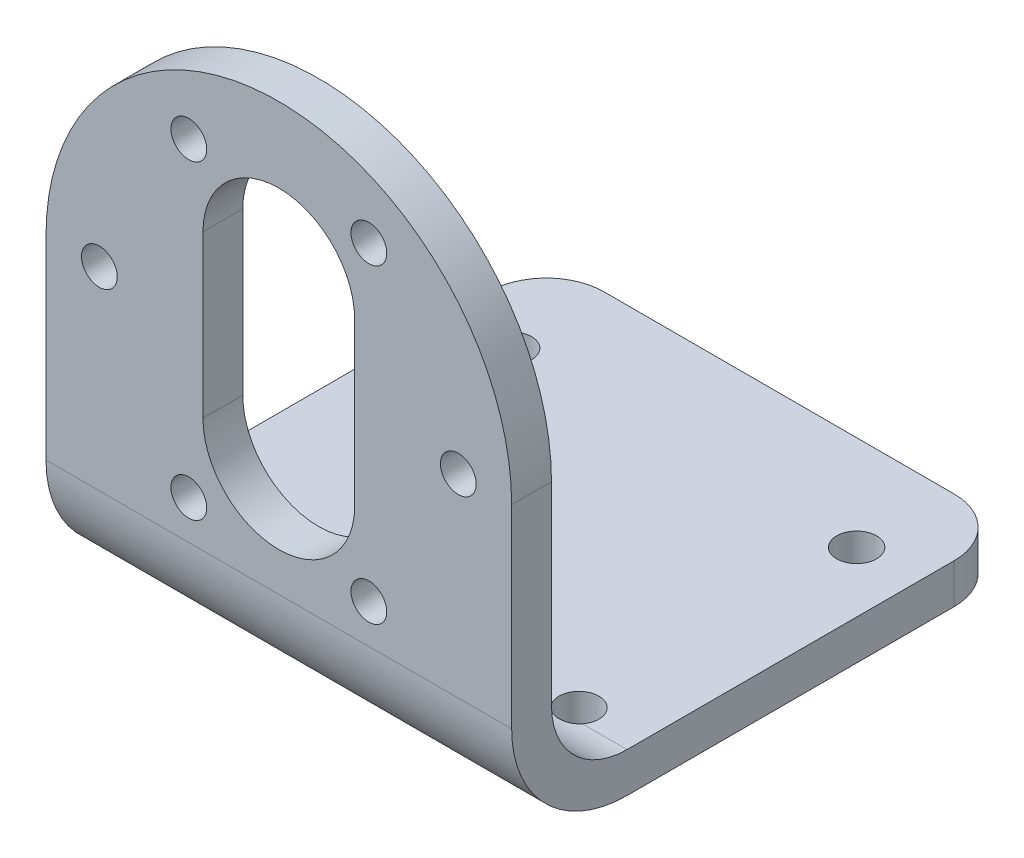
from build123d import *

# Parameters (mm, degrees)
SKETCH1_W               = 40.35
SKETCH1_H               = 43.35
BOSS_EXTRUDE1_DEPTH     = 47
CUT_EXTRUDE2_DEPTH      = 102
FILLET1_R               = 10
CUT_EXTRUDE3_DEPTH      = 102
FILLET2_R               = 5
CUT_EXTRUDE4_DEPTH      = 102
CUT_EXTRUDE4_DEPTH_BACK = 102
SKETCH6_R               = 1.73
CUT_EXTRUDE5_DEPTH      = 102
SKETCH8_R               = 1.55
CUT_EXTRUDE6_DEPTH      = 102


with BuildPart() as part:
    # Sketch1 → Boss-Extrude1 (new body)
    with BuildSketch(Plane(origin=(0, 0, 0), x_dir=(1, 0, 0), z_dir=(0, 1, 0))):
        with Locations((-26.966212793, -29.108023223)):
            Rectangle(SKETCH1_W, SKETCH1_H)
    extrude(amount=BOSS_EXTRUDE1_DEPTH)

    # Sketch3 → Cut-Extrude2 (cut)
    with BuildSketch(Plane.XY.offset(50.783023223)):
        with BuildLine():
            Line((-6.791212793, 47), (-26.966212793, 47))
            ThreePointArc((-26.966212793, 47), (-12.700333482, 41.09087931), (-6.791212793, 26.825))
            Line((-6.791212793, 26.825), (-6.791212793, 47))
        make_face()
        with BuildLine():
            Line((-47.141212793, 47), (-47.141212793, 26.825))
            ThreePointArc((-47.141212793, 26.825), (-41.232092103, 41.09087931), (-26.966212793, 47))
            Line((-26.966212793, 47), (-47.141212793, 47))
        make_face()
    extrude(amount=-CUT_EXTRUDE2_DEPTH, mode=Mode.SUBTRACT)

    # Fillet1
    fillet1_edges = [part.edges().sort_by_distance(p)[0] for p in [
        (-26.966212793, 0, 50.783023223),
    ]]
    fillet(fillet1_edges, radius=FILLET1_R)

    # Sketch5 → Cut-Extrude3 (cut)
    with BuildSketch(Plane.ZY.offset(47.141212793)):
        with BuildLine():
            Line((47.333023223, 59.778436909), (-6.665763497, 59.778436909))
            Line((-6.665763497, 59.778436909), (-6.665763497, 3.45))
            Line((-6.665763497, 3.45), (40.783023223, 3.45))
            ThreePointArc((40.783023223, 3.45), (45.41457264, 5.368450583), (47.333023223, 10))
            Line((47.333023223, 10), (47.333023223, 59.778436909))
        make_face()
    extrude(amount=-CUT_EXTRUDE3_DEPTH, mode=Mode.SUBTRACT)

    # Fillet2
    fillet2_edges = [part.edges().sort_by_distance(p)[0] for p in [
        (-6.791212793, 1.725, 7.433023223),
        (-47.141212793, 1.725, 7.433023223),
    ]]
    fillet(fillet2_edges, radius=FILLET2_R)

    # Sketch6 → Cut-Extrude4 (cut, two sides: drawn at the far end of the back side and taken through both)
    with BuildSketch(Plane(origin=(0, 3.45, 0), x_dir=(1, 0, 0), z_dir=(0, 1, 0)).offset(-CUT_EXTRUDE4_DEPTH_BACK)):
        with Locations((-41.911212793, -15.663023223)):
            Circle(SKETCH6_R)
        with Locations((-41.911212793, -39.723023223)):
            Circle(SKETCH6_R)
        with Locations((-12.021212793, -15.663023223)):
            Circle(SKETCH6_R)
        with Locations((-12.021212793, -39.723023223)):
            Circle(SKETCH6_R)
    extrude(amount=CUT_EXTRUDE4_DEPTH + CUT_EXTRUDE4_DEPTH_BACK, mode=Mode.SUBTRACT)

    # Sketch7 → Cut-Extrude5 (cut)
    with BuildSketch(Plane.XY.offset(50.783023223)):
        with BuildLine():
            ThreePointArc((-26.966212793, 40.5), (-31.615439879, 38.574227086), (-33.541212793, 33.925))
            Line((-33.541212793, 33.925), (-33.541212793, 21.982917389))
            Line((-33.541212793, 21.982917389), (-33.541212793, 19.945))
            ThreePointArc((-33.541212793, 19.945), (-26.966212793, 13.37), (-20.391212793, 19.945))
            Line((-20.391212793, 19.945), (-20.391212793, 20.41689663))
            Line((-20.391212793, 20.41689663), (-20.391212793, 33.925))
            ThreePointArc((-20.391212793, 33.925), (-22.316985706, 38.574227086), (-26.966212793, 40.5))
        make_face()
    extrude(amount=-CUT_EXTRUDE5_DEPTH, mode=Mode.SUBTRACT)

    # Sketch8 → Cut-Extrude6 (cut)
    with BuildSketch(Plane.XY.offset(50.783023223)):
        with Locations((-42.516212793, 26.825)):
            Circle(SKETCH8_R)
        with Locations((-34.766212793, 40.277230298)):
            Circle(SKETCH8_R)
        with Locations((-34.766212793, 13.372769702)):
            Circle(SKETCH8_R)
        with Locations((-19.166212793, 13.372769702)):
            Circle(SKETCH8_R)
        with Locations((-11.416212793, 26.825)):
            Circle(SKETCH8_R)
        with Locations((-19.166212793, 40.277230298)):
            Circle(SKETCH8_R)
    extrude(amount=-CUT_EXTRUDE6_DEPTH, mode=Mode.SUBTRACT)


solid = part.part
